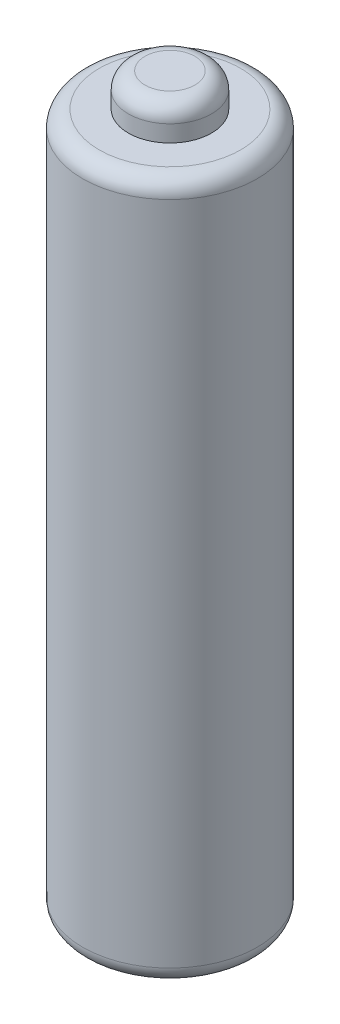
from build123d import *

# Parameters (mm, degrees)
SKETCH1_R           = 5.25
BOSS_EXTRUDE1_DEPTH = 42
SKETCH2_R           = 2.5
BOSS_EXTRUDE2_DEPTH = 2
FILLET1_R           = 1


with BuildPart() as part:
    # Sketch1 → Boss-Extrude1 (new body)
    with BuildSketch(Plane(origin=(0, 0, 0), x_dir=(1, 0, 0), z_dir=(0, 1, 0))):
        Circle(SKETCH1_R)
    extrude(amount=BOSS_EXTRUDE1_DEPTH)

    # Sketch2 → Boss-Extrude2 (add)
    with BuildSketch(Plane(origin=(0, 42, 0), x_dir=(1, 0, 0), z_dir=(0, 1, 0))):
        Circle(SKETCH2_R)
    extrude(amount=BOSS_EXTRUDE2_DEPTH)

    # Fillet1
    fillet1_edges = [part.edges().sort_by_distance(p)[0] for p in [
        (-5.25, 0, 0),
        (-5.25, 42, 0),
        (-2.5, 44, 0),
    ]]
    fillet(fillet1_edges, radius=FILLET1_R)


solid = part.part
